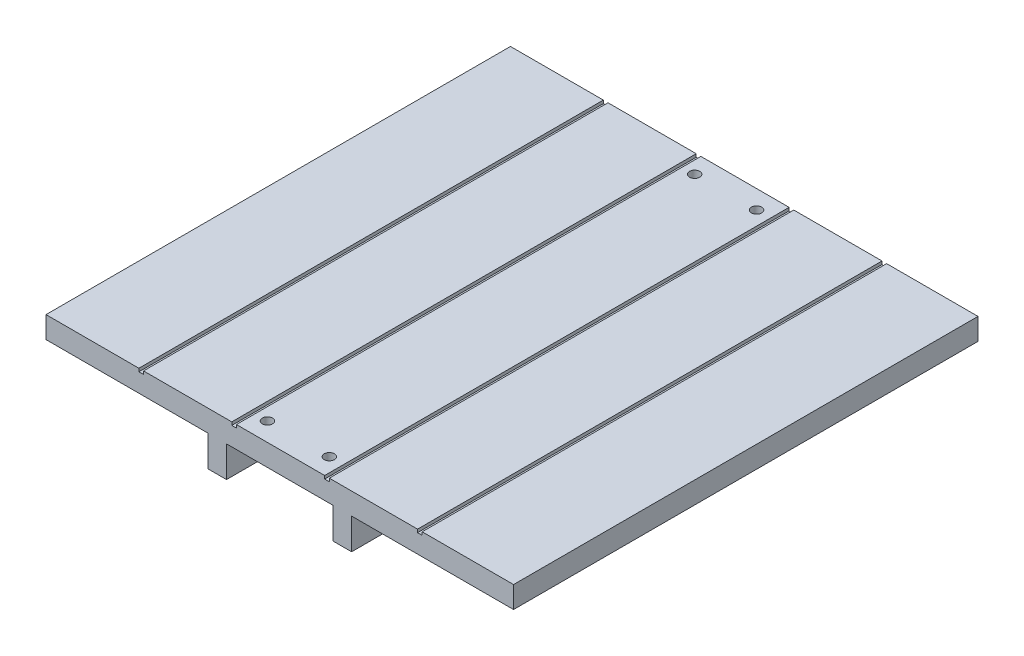
from build123d import *

# Parameters (mm, degrees)
BOSS_EXTRUDE1_DEPTH = 150
SKETCH4_R           = 1.65
CUT_EXTRUDE1_DEPTH  = 7
SKETCH5_W           = 1.5
SKETCH5_H           = 150
CUT_EXTRUDE2_DEPTH  = 1


with BuildPart() as part:
    # Sketch1 → Boss-Extrude1 (new body)
    with BuildSketch(Plane.XY):
        Polygon((-75.5, 3.5), (75.5, 3.5), (75.5, -3.5), (23.2, -3.5), (23.2, -13.5), (17.2, -13.5), (17.2, -3.5), (-17.2, -3.5), (-17.2, -13.5), (-23.2, -13.5), (-23.2, -3.5), (-75.5, -3.5), align=None)
    extrude(amount=BOSS_EXTRUDE1_DEPTH)

    # Sketch4 → Cut-Extrude1 (cut)
    with BuildSketch(Plane.XZ.offset(3.5)):
        with Locations((-10, 6)):
            Circle(SKETCH4_R)
        with Locations((10, 6)):
            Circle(SKETCH4_R)
        with Locations((-10, 144)):
            Circle(SKETCH4_R)
        with Locations((10, 144)):
            Circle(SKETCH4_R)
    extrude(amount=-CUT_EXTRUDE1_DEPTH, mode=Mode.SUBTRACT)

    # Sketch5 → Cut-Extrude2 (cut)
    with BuildSketch(Plane(origin=(0, 3.5, 0), x_dir=(1, 0, 0), z_dir=(0, 1, 0))):
        with Locations((-44.75, -75)):
            Rectangle(SKETCH5_W, SKETCH5_H)
        with Locations((-14.75, -75)):
            Rectangle(SKETCH5_W, SKETCH5_H)
        with Locations((15.25, -75)):
            Rectangle(SKETCH5_W, SKETCH5_H)
        with Locations((45.25, -75)):
            Rectangle(SKETCH5_W, SKETCH5_H)
    extrude(amount=-CUT_EXTRUDE2_DEPTH, mode=Mode.SUBTRACT)


solid = part.part
